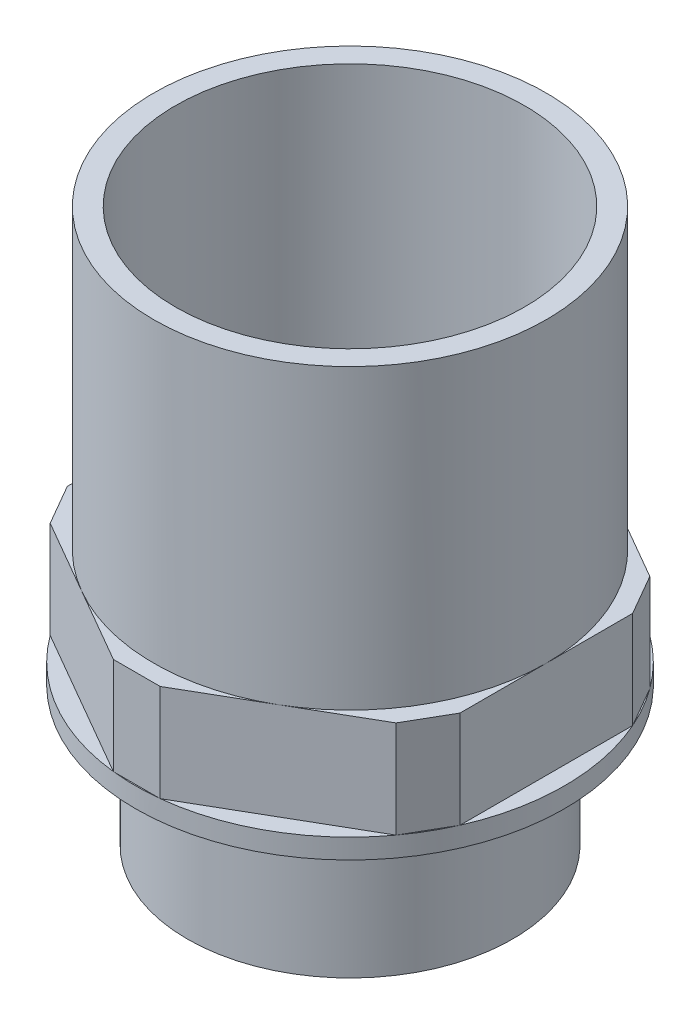
from build123d import *

# Parameters (mm, degrees)
SKETCH2_R           = 20.828
BASE_EXTRUDE_DEPTH  = 17.78
SKETCH3_R           = 27.4701
BOSS_EXTRUDE1_DEPTH = 2.54
BOSS_EXTRUDE3_DEPTH = 12.446
SKETCH6_R           = 25.146
BOSS_EXTRUDE4_DEPTH = 38.1
SKETCH7_R           = 22.352
CUT_EXTRUDE1_DEPTH  = 50.546
SKETCH8_R           = 17.145
CUT_EXTRUDE2_DEPTH  = 71.866


with BuildPart() as part:
    # Sketch2 → Base-Extrude (new body)
    with BuildSketch(Plane(origin=(0, 0, 0), x_dir=(1, 0, 0), z_dir=(0, 1, 0))):
        Circle(SKETCH2_R)
    extrude(amount=BASE_EXTRUDE_DEPTH)

    # Sketch3 → Boss-Extrude1 (add)
    with BuildSketch(Plane(origin=(0, 17.78, 0), x_dir=(-1, 0, 0), z_dir=(0, 1, 0))):
        Circle(SKETCH3_R)
    extrude(amount=BOSS_EXTRUDE1_DEPTH)

    # Sketch5 → Boss-Extrude3 (add)
    with BuildSketch(Plane(origin=(0, 20.32, 0), x_dir=(-1, 0, 0), z_dir=(0, 1, 0))):
        Polygon((25.146, -11.058258362), (25.146, 11.058258362), (22.149732663, 16.247945622), (2.996267337, 27.306203985), (-2.996267337, 27.306203985), (-22.149732663, 16.247945622), (-25.146, 11.058258362), (-25.146, -11.058258362), (-22.149732663, -16.247945622), (-2.996267337, -27.306203985), (2.996267337, -27.306203985), (22.149732663, -16.247945622), align=None)
    extrude(amount=BOSS_EXTRUDE3_DEPTH)

    # Sketch6 → Boss-Extrude4 (add)
    with BuildSketch(Plane(origin=(0, 32.766, 0), x_dir=(-1, 0, 0), z_dir=(0, 1, 0))):
        Circle(SKETCH6_R)
    extrude(amount=BOSS_EXTRUDE4_DEPTH)

    # Sketch7 → Cut-Extrude1 (cut)
    with BuildSketch(Plane(origin=(0, 70.866, 0), x_dir=(-1, 0, 0), z_dir=(0, 1, 0))):
        Circle(SKETCH7_R)
    extrude(amount=-CUT_EXTRUDE1_DEPTH, mode=Mode.SUBTRACT)

    # Sketch8 → Cut-Extrude2 (cut, through all)
    with BuildSketch(Plane.XZ):
        Circle(SKETCH8_R)
    extrude(amount=-CUT_EXTRUDE2_DEPTH, mode=Mode.SUBTRACT)


solid = part.part
